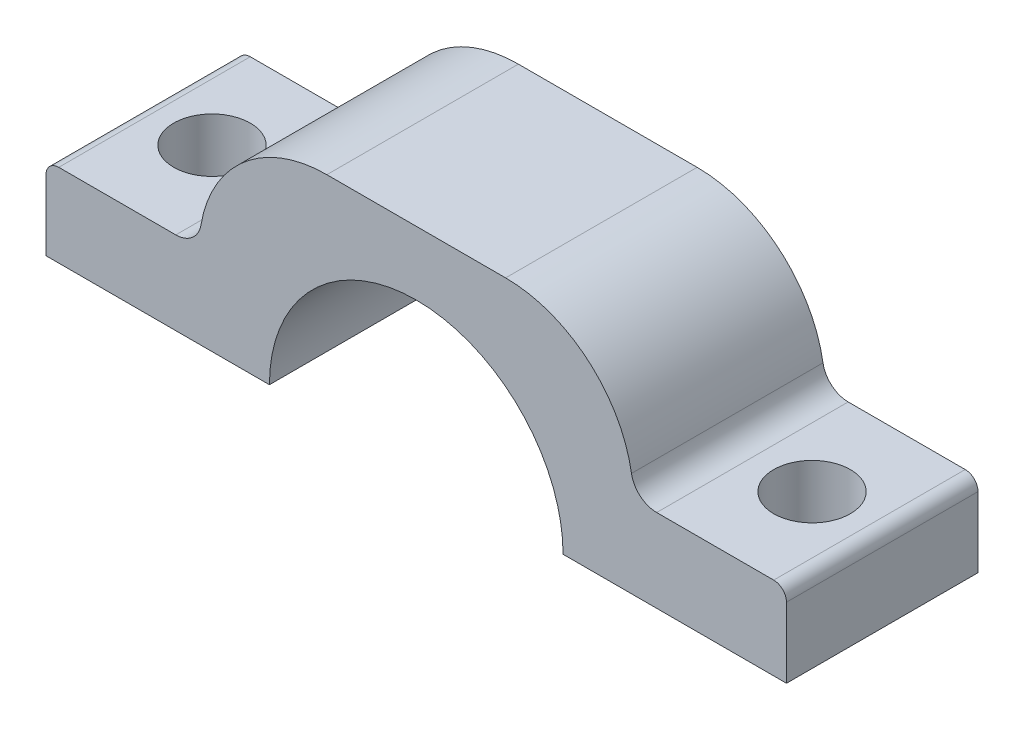
from build123d import *

# Parameters (mm, degrees)
DODANIE_WYCI_GNI_CIE1_DEPTH = 15
ZAOKR_GLENIE1_R             = 2
OTWORY_USTALAJ_CE_6_0MM3_D  = 6
ZAOKR_GLENIE2_R             = 1


with BuildPart() as part:
    # Szkic1 → Dodanie-wyciągnięcie1 (new body)
    with BuildSketch(Plane.XY):
        with BuildLine():
            Line((-29, 0), (-29, 6.5))
            Line((-29, 6.5), (-17, 6.5))
            ThreePointArc((-17, 6.5), (-14.071067812, 13.571067812), (-7, 16.5))
            Line((-7, 16.5), (7, 16.5))
            ThreePointArc((7, 16.5), (14.071067812, 13.571067812), (17, 6.5))
            Line((17, 6.5), (29, 6.5))
            Line((29, 6.5), (29, 0))
            Line((29, 0), (11.5, 0))
            ThreePointArc((11.5, 0), (0, 11.5), (-11.5, 0))
            Line((-11.5, 0), (-29, 0))
        make_face()
    extrude(amount=DODANIE_WYCI_GNI_CIE1_DEPTH)

    # Zaokrąglenie1
    zaokr_glenie1_edges = [part.edges().sort_by_distance(p)[0] for p in [
        (-17, 6.5, 7.5),
        (17, 6.5, 7.5),
    ]]
    fillet(zaokr_glenie1_edges, radius=ZAOKR_GLENIE1_R)

    # Otwory ustalające Ø6.0mm3 (through all)
    with Locations(Plane(origin=(0, 6.5, 0), x_dir=(1, 0, 0), z_dir=(0, 1, 0))):
        with Locations((-23.5, -7.5)):
            otwory_ustalaj_ce_6_0mm3 = Hole(OTWORY_USTALAJ_CE_6_0MM3_D / 2)

    # Lustro1: Otwory ustalające Ø6.0mm3 across plane
    add(otwory_ustalaj_ce_6_0mm3.mirror(Plane(origin=(0, 0, 0), x_dir=(0, 0, 1), z_dir=(1, 0, 0))), mode=Mode.SUBTRACT)

    # Zaokrąglenie2
    zaokr_glenie2_edges = [part.edges().sort_by_distance(p)[0] for p in [
        (29, 6.5, 7.5),
        (-29, 6.5, 7.5),
    ]]
    fillet(zaokr_glenie2_edges, radius=ZAOKR_GLENIE2_R)


solid = part.part
